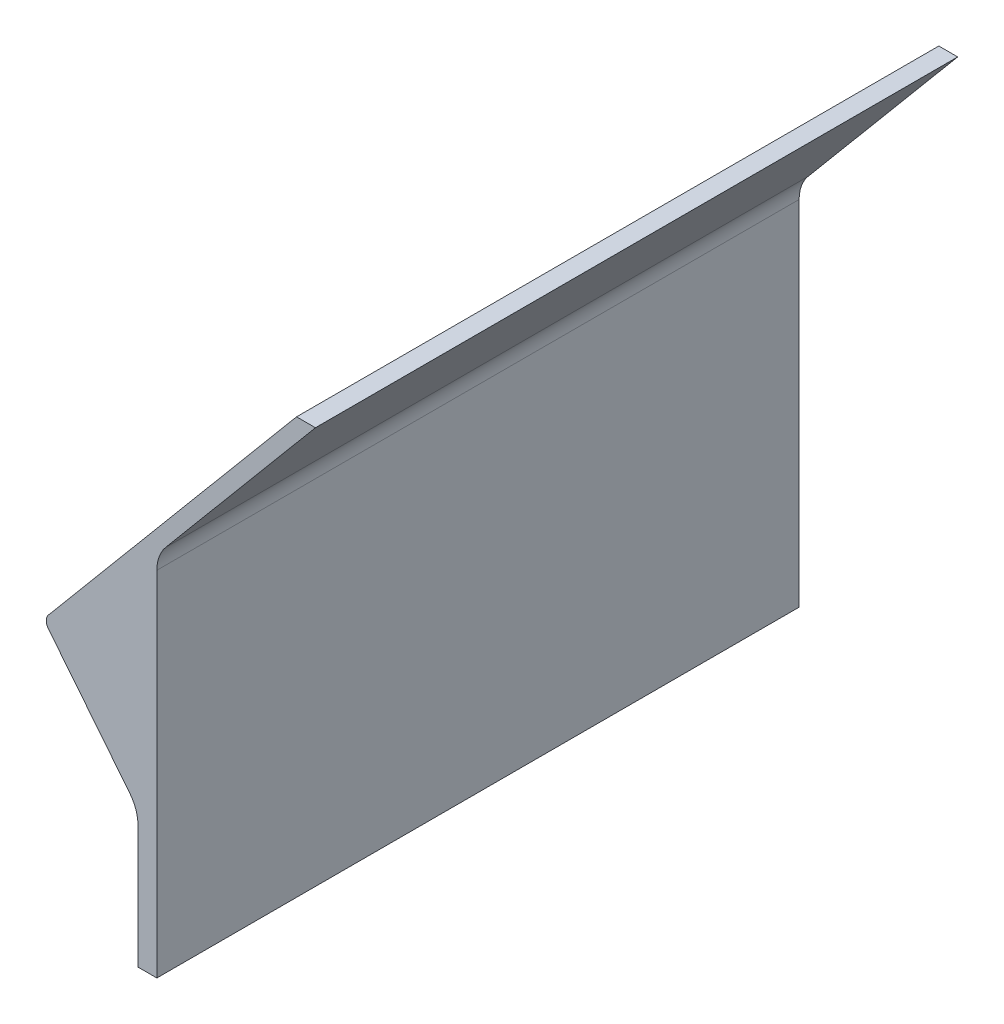
from build123d import *

# Parameters (mm, degrees)
FUNNEL_RIGHT_SIDE_DEPTH = 170
FILLET2_R               = 10
FILLET3_R               = 2.5


with BuildPart() as part:
    # Sketch1 → Funnel - Right Side (new body)
    with BuildSketch(Plane.XY):
        Polygon((0, 0), (0, 97.1), (41.974030913, 147.122702136), (36.974030913, 147.122702136), (-30, 67.306160185), (-5, 36.081170193), (-5, 0), align=None)
    extrude(amount=FUNNEL_RIGHT_SIDE_DEPTH)

    # Fillet2
    fillet2_edges = [part.edges().sort_by_distance(p)[0] for p in [
        (-5, 36.081170193, 85),
        (0, 97.1, 85),
    ]]
    fillet(fillet2_edges, radius=FILLET2_R)

    # Fillet3
    fillet3_edges = [part.edges().sort_by_distance(p)[0] for p in [
        (-30, 67.306160185, 85),
    ]]
    fillet(fillet3_edges, radius=FILLET3_R)


solid = part.part
